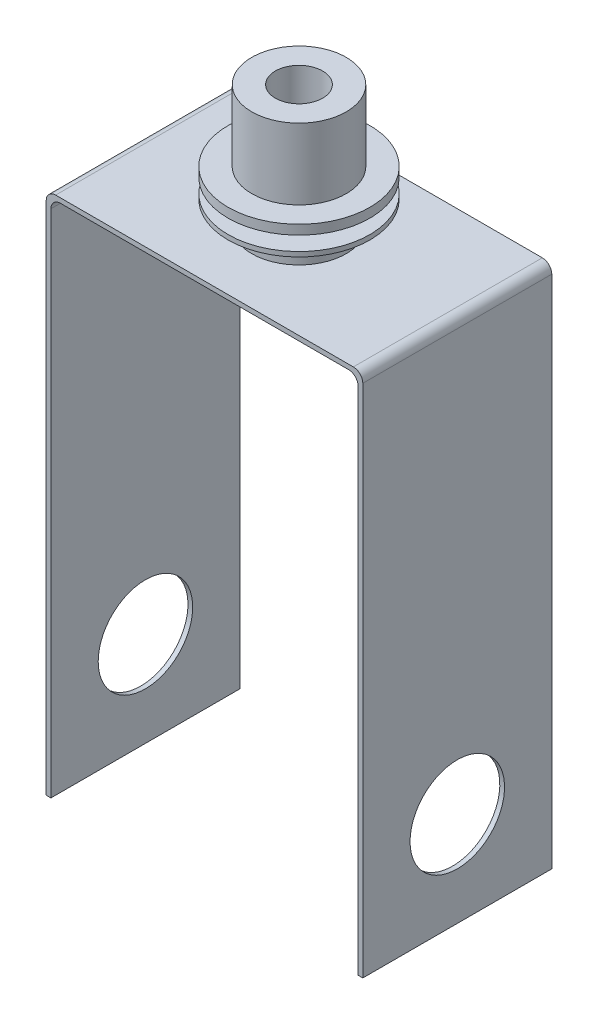
from build123d import *

# Parameters (mm, degrees)
BOSS_EXTRUDE1_DEPTH = 50.8
SKETCH2_R           = 12.7
CUT_EXTRUDE1_DEPTH  = 86.09
SKETCH3_R           = 12.7
BOSS_EXTRUDE2_DEPTH = 6.35
SKETCH4_R           = 19.05
BOSS_EXTRUDE3_DEPTH = 1.27
SKETCH5_R           = 12.7
BOSS_EXTRUDE4_DEPTH = 25.4
SKETCH6_R           = 6.35
CUT_EXTRUDE2_DEPTH  = 174.99
SKETCH7_R           = 19.05
SKETCH7_R_2         = 12.7
BOSS_EXTRUDE5_DEPTH = 2.54


with BuildPart() as part:
    # Sketch1 → Boss-Extrude1 (new body)
    with BuildSketch(Plane.XY):
        with BuildLine():
            Line((42.545, 113.03), (42.545, -25.4))
            Line((42.545, -25.4), (41.275, -25.4))
            Line((41.275, -25.4), (41.275, 111.76))
            ThreePointArc((41.275, 111.76), (40.531051224, 113.556051224), (38.735, 114.3))
            Line((38.735, 114.3), (-38.735, 114.3))
            ThreePointArc((-38.735, 114.3), (-40.531051224, 113.556051224), (-41.275, 111.76))
            Line((-41.275, 111.76), (-41.275, -25.4))
            Line((-41.275, -25.4), (-42.545, -25.4))
            Line((-42.545, -25.4), (-42.545, 113.03))
            ThreePointArc((-42.545, 113.03), (-41.801051224, 114.826051224), (-40.005, 115.57))
            Line((-40.005, 115.57), (40.005, 115.57))
            ThreePointArc((40.005, 115.57), (41.801051224, 114.826051224), (42.545, 113.03))
        make_face()
    extrude(amount=BOSS_EXTRUDE1_DEPTH)

    # Sketch2 → Cut-Extrude1 (cut, through all)
    with BuildSketch(Plane.ZY.offset(42.545)):
        with Locations((25.4, 0)):
            Circle(SKETCH2_R)
    extrude(amount=-CUT_EXTRUDE1_DEPTH, mode=Mode.SUBTRACT)

    # Sketch3 → Boss-Extrude2 (add)
    with BuildSketch(Plane(origin=(0, 115.57, 0), x_dir=(1, 0, 0), z_dir=(0, 1, 0))):
        with Locations((0, -25.4)):
            Circle(SKETCH3_R)
    extrude(amount=BOSS_EXTRUDE2_DEPTH)

    # Sketch4 → Boss-Extrude3 (add)
    with BuildSketch(Plane(origin=(0, 121.92, 0), x_dir=(1, 0, 0), z_dir=(0, 1, 0))):
        with Locations((0, -25.4)):
            Circle(SKETCH4_R)
    extrude(amount=BOSS_EXTRUDE3_DEPTH)

    # Sketch5 → Boss-Extrude4 (add)
    with BuildSketch(Plane(origin=(0, 123.19, 0), x_dir=(1, 0, 0), z_dir=(0, 1, 0))):
        with Locations((0, -25.4)):
            Circle(SKETCH5_R)
    extrude(amount=BOSS_EXTRUDE4_DEPTH)

    # Sketch6 → Cut-Extrude2 (cut, through all)
    with BuildSketch(Plane(origin=(0, 148.59, 0), x_dir=(1, 0, 0), z_dir=(0, 1, 0))):
        with Locations((0, -25.4)):
            Circle(SKETCH6_R)
    extrude(amount=-CUT_EXTRUDE2_DEPTH, mode=Mode.SUBTRACT)

    # Sketch7 → Boss-Extrude5 (add)
    with BuildSketch(Plane(origin=(0, 127, 0), x_dir=(1, 0, 0), z_dir=(0, 1, 0))):
        with Locations((0, -25.4)):
            Circle(SKETCH7_R)
        with Locations((0, -25.4)):
            Circle(SKETCH7_R_2, mode=Mode.SUBTRACT)
    extrude(amount=BOSS_EXTRUDE5_DEPTH)


solid = part.part
